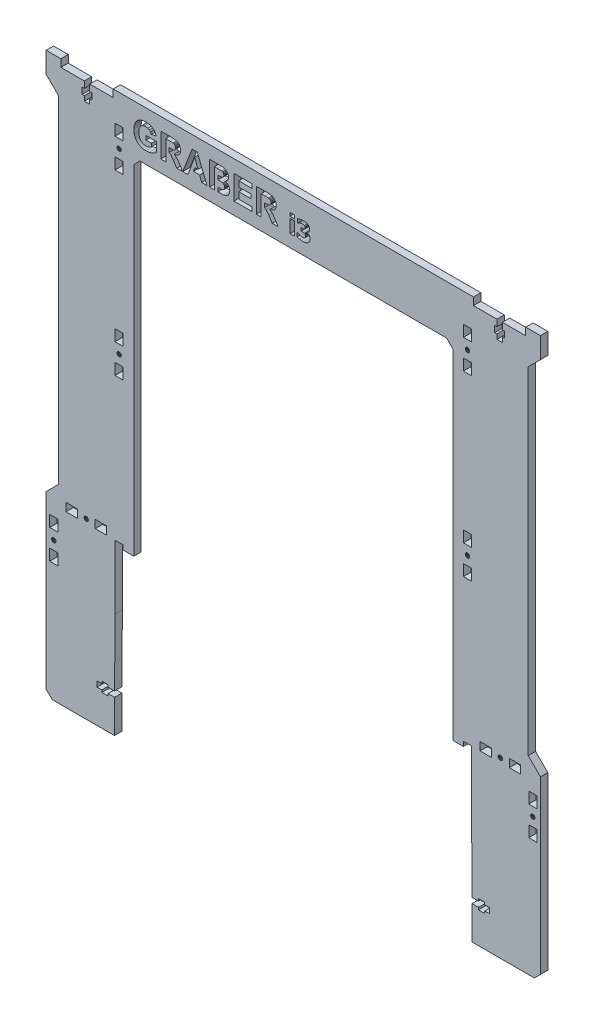
from build123d import *

# Parameters (mm, degrees)
SKETCH1_W           = 9.1999977
SKETCH1_H           = 6.599987016
SKETCH1_W_2         = 9.199995837
SKETCH1_W_3         = 6.600001917
SKETCH1_H_2         = 9.1999977
SKETCH1_W_4         = 6.600001918
SKETCH1_H_3         = 9.199995838
SKETCH1_H_4         = 9.199995837
SKETCH1_W_5         = 9.199997699
SKETCH1_W_6         = 3.544061303
SKETCH1_H_5         = 2.614942529
SKETCH1_W_7         = 3.352490421
SKETCH1_H_6         = 10.756704981
BOSS_EXTRUDE1_DEPTH = 6


with BuildPart() as part:
    # Sketch1 → Boss-Extrude1 (new body)
    with BuildSketch(Plane.XY):
        Polygon((502.477651433, 83.050254715), (493.827654201, 83.050254715), (493.827654201, 359.540924035), (488.827655801, 364.540922435), (238.827735801, 364.540922435), (233.827737401, 359.540924035), (233.827737401, 83.050254715), (225.177740169, 83.050254715), (225.177740169, 86.741023859), (218.477742313, 86.741023859), (218.477742313, 34.550270235), (218.169531771, -19.958979321), (212.869532949, -19.958979321), (212.869532949, -18.158981089), (207.769535184, -18.158981089), (207.769535184, -19.958979321), (203.819535362, -19.958979321), (203.819535362, -24.358983993), (207.769535184, -24.358983993), (207.769535184, -26.158982225), (212.869532949, -26.158982225), (212.869532949, -24.358983993), (218.169531771, -24.358983993), (218.027745865, -51.458971965), (167.377754014, -51.458971965), (162.377755614, -46.650721918), (162.377755614, 93.041023355), (172.377754814, 103.041022555), (172.377754814, 377.540911795), (162.377755614, 387.540910995), (162.377755614, 404.540909635), (174.377752254, 404.540909635), (174.377752254, 398.440911587), (193.477734582, 398.440911587), (193.477734582, 393.140912766), (191.67773635, 393.140912766), (191.67773635, 388.040915001), (193.477734582, 388.040915001), (193.477734582, 384.090915179), (197.877739254, 384.090915179), (197.877739254, 388.040915001), (199.677737486, 388.040915001), (199.677737486, 393.140912766), (197.877739254, 393.140912766), (197.877739254, 398.440911587), (216.977735214, 398.440911587), (216.977735214, 404.540909635), (510.727648313, 404.540909635), (510.727648313, 398.440911587), (529.827644273, 398.440911587), (529.827644273, 393.140912766), (528.027646041, 393.140912766), (528.027646041, 388.040915001), (529.827644273, 388.040915001), (529.827644273, 384.090915179), (534.227648945, 384.090915179), (534.227648945, 388.040915001), (536.027647177, 388.040915001), (536.027647177, 393.140912766), (534.227648945, 393.140912766), (534.227648945, 398.440911587), (553.327631273, 398.440911587), (553.327631273, 404.540909635), (565.327627913, 404.540909635), (565.327627913, 387.540910995), (555.327628713, 377.540911795), (555.327628713, 103.041022555), (565.327627913, 93.041023355), (565.327627913, -46.458973565), (560.327629513, -51.458971965), (509.627645737, -51.458971965), (509.50161394, -24.358983993), (514.801612761, -24.358983993), (514.801612761, -26.158982225), (519.901610526, -26.158982225), (519.901610526, -24.358983993), (523.851610348, -24.358983993), (523.851610348, -19.958979321), (519.901610526, -19.958979321), (519.901610526, -18.158981089), (514.801612761, -18.158981089), (514.801612761, -19.958979321), (509.50161394, -19.958979321), (509.227649273, 34.550270235), (509.227649273, 86.741023859), (502.477651433, 86.741023859), align=None)
        Polygon((223.101753359, 365.909146328), (222.728603849, 366.195474018), (222.294062041, 366.375467128), (221.827741241, 366.436859426), (221.361420441, 366.375467128), (220.926878633, 366.195474018), (220.553729123, 365.909146328), (220.267401433, 365.535996818), (220.087408323, 365.10145501), (220.026016025, 364.635134211), (220.087408323, 364.168813411), (220.267401433, 363.734271603), (220.553729123, 363.361122093), (220.926878633, 363.074794403), (221.361420441, 362.894801293), (221.827741241, 362.833408995), (222.294062041, 362.894801293), (222.728603849, 363.074794403), (223.101753359, 363.361122093), (223.388081048, 363.734271603), (223.568074158, 364.168813411), (223.629466456, 364.635134211), (223.568074158, 365.10145501), (223.388081048, 365.535996818), align=None, mode=Mode.SUBTRACT)
        Polygon((220.026016025, 219.550211035), (220.087408323, 219.083890236), (220.267401433, 218.649348428), (220.553729123, 218.276198918), (220.926878633, 217.989871228), (221.361420441, 217.809878118), (221.827741241, 217.74848582), (222.294062041, 217.809878118), (222.728603849, 217.989871228), (223.101753359, 218.276198918), (223.388081048, 218.649348428), (223.568074158, 219.083890236), (223.629466456, 219.550211035), (223.568074158, 220.016531835), (223.388081048, 220.451073643), (223.101753359, 220.824223153), (222.728603849, 221.110550843), (222.294062041, 221.290543953), (221.827741241, 221.351936251), (221.361420441, 221.290543953), (220.926878633, 221.110550843), (220.553729123, 220.824223153), (220.267401433, 220.451073643), (220.087408323, 220.016531835), align=None, mode=Mode.SUBTRACT)
        Polygon((507.567983278, 364.168813411), (507.629375576, 364.635134211), (507.567983278, 365.10145501), (507.387990168, 365.535996818), (507.101662479, 365.909146328), (506.728512969, 366.195474018), (506.293971161, 366.375467128), (505.827650361, 366.436859426), (505.361329561, 366.375467128), (504.926787753, 366.195474018), (504.553638243, 365.909146328), (504.267310553, 365.535996818), (504.087317443, 365.10145501), (504.025925145, 364.635134211), (504.087317443, 364.168813411), (504.267310553, 363.734271603), (504.553638243, 363.361122093), (504.926787753, 363.074794403), (505.361329561, 362.894801293), (505.827650361, 362.833408995), (506.293971161, 362.894801293), (506.728512969, 363.074794403), (507.101662479, 363.361122093), (507.387990168, 363.734271603), align=None, mode=Mode.SUBTRACT)
        with Locations((183.17775488, 90.090946608)):
            Rectangle(SKETCH1_W, SKETCH1_H, mode=Mode.SUBTRACT)
        with Locations((206.97774571, 90.090946608)):
            Rectangle(SKETCH1_W_2, SKETCH1_H, mode=Mode.SUBTRACT)
        with Locations((559.077635956, 49.890967072)):
            Rectangle(SKETCH1_W_3, SKETCH1_H_2, mode=Mode.SUBTRACT)
        with Locations((221.82774028, 352.735139431)):
            Rectangle(SKETCH1_W_4, SKETCH1_H_2, mode=Mode.SUBTRACT)
        with Locations((221.82774028, 376.535130261)):
            Rectangle(SKETCH1_W_4, SKETCH1_H_3, mode=Mode.SUBTRACT)
        Polygon((559.543957717, 63.531294769), (559.077636918, 63.592687067), (558.611316118, 63.531294769), (558.17677431, 63.351301658), (557.8036248, 63.064973969), (557.51729711, 62.691824459), (557.337304, 62.257282651), (557.275911702, 61.790961851), (557.337304, 61.324641051), (557.51729711, 60.890099243), (557.8036248, 60.516949733), (558.17677431, 60.230622044), (558.611316118, 60.050628933), (559.077636918, 59.989236635), (559.543957717, 60.050628933), (559.978499525, 60.230622044), (560.351649035, 60.516949733), (560.637976725, 60.890099243), (560.817969835, 61.324641051), (560.879362133, 61.790961851), (560.817969835, 62.257282651), (560.637976725, 62.691824459), (560.351649035, 63.064973969), (559.978499525, 63.351301658), align=None, mode=Mode.SUBTRACT)
        Polygon((170.318089523, 61.324641051), (170.379481821, 61.790961851), (170.318089523, 62.257282651), (170.138096413, 62.691824459), (169.851768723, 63.064973969), (169.478619213, 63.351301658), (169.044077406, 63.531294769), (168.577756606, 63.592687067), (168.111435806, 63.531294769), (167.676893998, 63.351301658), (167.303744488, 63.064973969), (167.017416798, 62.691824459), (166.837423688, 62.257282651), (166.77603139, 61.790961851), (166.837423688, 61.324641051), (167.017416798, 60.890099243), (167.303744488, 60.516949733), (167.676893998, 60.230622044), (168.111435806, 60.050628933), (168.577756606, 59.989236635), (169.044077406, 60.050628933), (169.478619213, 60.230622044), (169.851768723, 60.516949733), (170.138096413, 60.890099243), align=None, mode=Mode.SUBTRACT)
        Polygon((193.337416742, 89.624627687), (193.517409852, 89.190085879), (193.803737542, 88.816936369), (194.176887052, 88.530608679), (194.61142886, 88.350615569), (195.077749659, 88.289223271), (195.544070459, 88.350615569), (195.978612267, 88.530608679), (196.351761777, 88.816936369), (196.638089467, 89.190085879), (196.818082577, 89.624627687), (196.879474875, 90.090948487), (196.818082577, 90.557269287), (196.638089467, 90.991811095), (196.351761777, 91.364960605), (195.978612267, 91.651288294), (195.544070459, 91.831281404), (195.077749659, 91.892673702), (194.61142886, 91.831281404), (194.176887052, 91.651288294), (193.803737542, 91.364960605), (193.517409852, 90.991811095), (193.337416742, 90.557269287), (193.276024444, 90.090948487), align=None, mode=Mode.SUBTRACT)
        Polygon((271.976630761, 388.692495359), (271.8953095, 387.634061422), (271.651345717, 386.672039289), (271.244739413, 385.80642896), (270.675490587, 385.037230436), (269.944437602, 384.382887713), (269.052418823, 383.861844789), (267.999434249, 383.474101663), (266.78548388, 383.219658337), (267.960869527, 382.431596633), (268.911573752, 381.56975894), (269.895812518, 380.322274031), (271.171801787, 378.377270677), (273.572874892, 374.540919235), (268.824383947, 374.540919235), (265.953827273, 378.819926613), (263.861271941, 381.710604011), (263.281124389, 382.213622119), (262.667442297, 382.528846801), (262.667442297, 385.889007766), (262.801580459, 385.889007766), (265.122170667, 385.94936994), (266.369655576, 386.130456459), (267.003458393, 386.459094956), (267.483002324, 386.962113065), (267.784813189, 387.626096968), (267.885416811, 388.43763285), (267.752955375, 389.334681811), (267.355571069, 390.04058389), (266.716738071, 390.538571817), (265.85993056, 390.811878323), (262.962546254, 390.878947404), (259.863954705, 390.878947404), (259.863954705, 374.540919235), (255.8934651, 374.540919235), (255.8934651, 394.20557383), (264.250272612, 394.20557383), (266.97160058, 394.073112394), (268.831090855, 393.675728088), (270.117140486, 392.939644923), (271.118146522, 391.791086908), (271.762009701, 390.339041301), align=None, mode=Mode.SUBTRACT)
        with Locations((221.82774028, 231.450207086)):
            Rectangle(SKETCH1_W_4, SKETCH1_H_4, mode=Mode.SUBTRACT)
        with Locations((221.82774028, 207.650216256)):
            Rectangle(SKETCH1_W_4, SKETCH1_H_2, mode=Mode.SUBTRACT)
        Polygon((533.901647358, 91.364960605), (533.528497848, 91.651288294), (533.09395604, 91.831281404), (532.62763524, 91.892673702), (532.16131444, 91.831281404), (531.726772632, 91.651288294), (531.353623122, 91.364960605), (531.067295432, 90.991811095), (530.887302322, 90.557269287), (530.825910024, 90.090948487), (530.887302322, 89.624627687), (531.067295432, 89.190085879), (531.353623122, 88.816936369), (531.726772632, 88.530608679), (532.16131444, 88.350615569), (532.62763524, 88.289223271), (533.09395604, 88.350615569), (533.528497848, 88.530608679), (533.901647358, 88.816936369), (534.187975047, 89.190085879), (534.367968157, 89.624627687), (534.429360455, 90.090948487), (534.367968157, 90.557269287), (534.187975047, 90.991811095), align=None, mode=Mode.SUBTRACT)
        with Locations((168.577755645, 49.890967072)):
            Rectangle(SKETCH1_W_3, SKETCH1_H_2, mode=Mode.SUBTRACT)
        with Locations((168.577755645, 73.690957902)):
            Rectangle(SKETCH1_W_3, SKETCH1_H_4, mode=Mode.SUBTRACT)
        with Locations((520.72764046, 90.090946608)):
            Rectangle(SKETCH1_W_5, SKETCH1_H, mode=Mode.SUBTRACT)
        with Locations((544.527631291, 90.090946608)):
            Rectangle(SKETCH1_W_2, SKETCH1_H, mode=Mode.SUBTRACT)
        with Locations((559.077635956, 73.690957902)):
            Rectangle(SKETCH1_W_3, SKETCH1_H_4, mode=Mode.SUBTRACT)
        Polygon((507.567983278, 220.016531835), (507.387990168, 220.451073643), (507.101662479, 220.824223153), (506.728512969, 221.110550843), (506.293971161, 221.290543953), (505.827650361, 221.351936251), (505.361329561, 221.290543953), (504.926787753, 221.110550843), (504.553638243, 220.824223153), (504.267310553, 220.451073643), (504.087317443, 220.016531835), (504.025925145, 219.550211035), (504.087317443, 219.083890236), (504.267310553, 218.649348428), (504.553638243, 218.276198918), (504.926787753, 217.989871228), (505.361329561, 217.809878118), (505.827650361, 217.74848582), (506.293971161, 217.809878118), (506.728512969, 217.989871228), (507.101662479, 218.276198918), (507.387990168, 218.649348428), (507.567983278, 219.083890236), (507.629375576, 219.550211035), align=None, mode=Mode.SUBTRACT)
        with Locations((505.8276494, 207.650216256)):
            Rectangle(SKETCH1_W_4, SKETCH1_H_2, mode=Mode.SUBTRACT)
        with Locations((505.8276494, 231.450207086)):
            Rectangle(SKETCH1_W_4, SKETCH1_H_4, mode=Mode.SUBTRACT)
        with Locations((505.8276494, 376.535130261)):
            Rectangle(SKETCH1_W_4, SKETCH1_H_3, mode=Mode.SUBTRACT)
        Polygon((236.701647528, 392.009061422), (237.718582471, 392.854970208), (238.88474612, 393.56171065), (239.888267247, 393.990114406), (241.007482538, 394.296117089), (243.592995617, 394.540919235), (245.323797092, 394.444926613), (246.854229688, 394.156948746), (248.184293403, 393.676985634), (249.313988239, 393.005037277), (250.25169783, 392.16373949), (251.005805811, 391.175728088), (251.576312183, 390.041003072), (251.963216945, 388.75956444), (248.019554973, 388.021804547), (247.420963424, 389.31791454), (246.456845382, 390.308860215), (245.167442297, 390.93763285), (243.592995617, 391.147223729), (242.358505342, 391.044105017), (241.257314866, 390.73474888), (240.289424188, 390.219155318), (239.45483331, 389.497324333), (238.782884953, 388.572609376), (238.302921841, 387.448363903), (238.014943974, 386.124587914), (237.918951351, 384.601281408), (238.016201519, 382.960184829), (238.307952022, 381.537901127), (238.79420286, 380.334430302), (239.474954034, 379.349772354), (240.313317548, 378.583927284), (241.272405409, 378.03689509), (242.352217615, 377.708675775), (243.552754168, 377.599269336), (244.801915805, 377.721670409), (246.054430895, 378.088873628), (247.21975618, 378.630456459), (248.2073484, 379.275996365), (248.2073484, 381.770966184), (243.660064698, 381.770966184), (243.660064698, 385.084178793), (252.218079453, 385.084178793), (252.218079453, 377.250510114), (250.69058113, 376.115365915), (248.603055979, 375.124420241), (246.220426871, 374.435285432), (243.807616676, 374.20557383), (242.314491257, 374.286475909), (240.920292733, 374.529182146), (239.625021103, 374.933692542), (238.428676368, 375.500007096), (237.353055979, 376.216807901), (236.419957387, 377.072777049), (235.629380593, 378.06791454), (234.981325597, 379.202220375), (234.476630761, 380.432518833), (234.11613445, 381.715634192), (233.827737401, 384.440315614), (233.908220298, 385.933441033), (234.14966899, 387.341053373), (234.552083477, 388.663152636), (235.115463759, 389.899738819), (235.833941291, 391.023984292), align=None, mode=Mode.SUBTRACT)
        Polygon((307.053760204, 374.675057398), (302.342023115, 374.543075967), (302.342023115, 377.854131844), (303.217408762, 377.854131844), (305.940413457, 377.97485619), (306.743565704, 378.25151615), (307.382398702, 378.75956444), (307.799903732, 379.488940697), (307.939072075, 380.429584561), (307.831761546, 381.247827351), (307.509829956, 381.931931978), (306.985014396, 382.465131174), (306.269051955, 382.830657666), (304.983002324, 383.041925272), (302.747925194, 383.112347807), (302.342023115, 383.112347807), (302.342023115, 386.389917098), (305.028273953, 386.452388048), (305.93873673, 386.688806559), (306.631224993, 387.1566134), (307.068850748, 387.832334393), (307.214725999, 388.692495359), (307.088971472, 389.519121784), (306.71170789, 390.174722052), (306.086288709, 390.632468531), (305.216067381, 390.865533588), (301.822371874, 390.932602669), (299.542023115, 390.932602669), (299.542023115, 374.540919235), (295.571533511, 374.540919235), (295.571533511, 394.20557383), (303.432029822, 394.20557383), (306.912915134, 394.011073494), (307.999434249, 393.710939356), (308.965229017, 393.199537612), (309.795208896, 392.480221717), (310.474283343, 391.556345124), (310.926999641, 390.468149282), (311.077905073, 389.25587564), (310.891788373, 387.931261288), (310.333438273, 386.720664373), (309.456510037, 385.711274701), (308.31465893, 384.990282079), (309.904196153, 384.282703273), (311.077905073, 383.20624452), (311.80225115, 381.834681811), (312.043699842, 380.241791133), (311.887764228, 378.918853508), (311.419957387, 377.632803876), (310.682197495, 376.492629497), (309.716402726, 375.607317626), (308.510835992, 374.99531226), align=None, mode=Mode.SUBTRACT)
        Polygon((341.121499976, 382.213622119), (340.507817884, 382.528846801), (340.504330291, 385.889007766), (340.641956046, 385.889007766), (342.962546254, 385.94936994), (344.210031163, 386.130456459), (344.84383398, 386.459094956), (345.323377911, 386.962113065), (345.625188776, 387.626096968), (345.725792397, 388.43763285), (345.593330962, 389.334681811), (345.195946656, 390.04058389), (344.557113658, 390.538571817), (343.700306147, 390.811878323), (340.802921841, 390.878947404), (337.704330291, 390.878947404), (337.704330291, 374.540919235), (333.733840687, 374.540919235), (333.733840687, 394.20557383), (342.090648199, 394.20557383), (344.811976167, 394.073112394), (346.671466442, 393.675728088), (347.957516073, 392.939644923), (348.958522109, 391.791086908), (349.602385288, 390.339041301), (349.817006348, 388.692495359), (349.735685087, 387.634061422), (349.491721304, 386.672039289), (349.085115, 385.80642896), (348.515866173, 385.037230436), (347.784813189, 384.382887713), (346.892794409, 383.861844789), (345.839809835, 383.474101663), (344.625859467, 383.219658337), (345.801245114, 382.431596633), (346.751949339, 381.56975894), (347.736188105, 380.322274031), (349.012177374, 378.377270677), (351.413250479, 374.540919235), (346.664759534, 374.540919235), (343.79420286, 378.819926613), (341.701647528, 381.710604011), align=None, mode=Mode.SUBTRACT)
        Polygon((282.353999305, 379.00772004), (283.574656582, 382.320932649), (286.141620701, 382.320932649), (283.432029822, 389.618048679), (277.932365167, 374.540919235), (273.720426871, 374.540919235), (281.379715939, 394.20557383), (285.578240419, 394.20557383), (293.452150546, 374.540919235), (289.13290172, 374.540919235), (287.415933242, 379.00772004), align=None, mode=Mode.SUBTRACT)
        Polygon((330.353558997, 374.540919235), (315.3971539, 374.540919235), (315.3971539, 394.20557383), (329.977972143, 394.20557383), (329.977972143, 390.878947404), (319.367643504, 390.878947404), (319.367643504, 386.519457129), (329.24021225, 386.519457129), (329.24021225, 383.20624452), (319.367643504, 383.20624452), (319.367643504, 377.854131844), (330.353558997, 377.854131844), align=None, mode=Mode.SUBTRACT)
        with Locations((505.8276494, 352.735139431)):
            Rectangle(SKETCH1_W_4, SKETCH1_H_2, mode=Mode.SUBTRACT)
        with Locations((363.012054787, 388.137662531)):
            Rectangle(SKETCH1_W_6, SKETCH1_H_5, mode=Mode.SUBTRACT)
        with Locations((363.012054787, 379.919271726)):
            Rectangle(SKETCH1_W_7, SKETCH1_H_6, mode=Mode.SUBTRACT)
        Polygon((371.910522219, 389.100306208), (373.099459001, 389.04522958), (374.118376625, 388.879999695), (374.984037545, 388.609405825), (375.713204212, 388.238237243), (376.350177392, 387.726982454), (376.805158235, 387.093601228), (377.07814674, 386.354856017), (377.169142909, 385.527509274), (376.993137162, 384.386465212), (376.46511992, 383.39628322), (375.649746357, 382.643170193), (374.611671645, 382.213333028), (374.611671645, 382.079233412), (375.603050955, 381.820612722), (376.546537545, 381.22674299), (376.940455169, 380.799300461), (377.260139077, 380.264099312), (377.472064365, 379.618744906), (377.542706127, 378.860842607), (377.445723369, 377.862279389), (377.154775093, 376.954712339), (376.677045208, 376.157298546), (376.019717622, 375.489195097), (375.19716015, 374.956388584), (374.242897698, 374.564865595), (373.111432181, 374.324204676), (371.757265514, 374.243984369), (370.20913333, 374.313428814), (368.898070112, 374.521762147), (366.95841494, 375.144367511), (366.95841494, 378.238237243), (367.303242526, 378.238237243), (368.156930265, 377.773677856), (369.147112258, 377.376168277), (370.158845974, 377.103179772), (371.077188886, 377.012183603), (372.202667813, 377.103179772), (372.761815323, 377.248055251), (373.222782756, 377.50068935), (373.744813407, 378.08976981), (373.892083522, 378.512423067), (373.94117356, 379.08114912), (373.871729116, 379.64029663), (373.663395782, 380.053371343), (373.34011992, 380.346714254), (372.92584789, 380.546666362), (371.824315323, 380.728658699), (370.694047123, 380.747815787), (370.081020304, 380.747815787), (370.081020304, 383.257394331), (370.646154403, 383.257394331), (371.843472411, 383.314865595), (372.772591185, 383.544750653), (373.371250189, 384.052413488), (373.53288812, 384.435555251), (373.58676743, 384.933639542), (373.536480074, 385.32516253), (373.385618005, 385.63766253), (372.887533713, 386.063907741), (372.082936012, 386.293792799), (371.297495399, 386.351264063), (370.224698464, 386.22674299), (369.161480074, 385.910651036), (368.318568196, 385.513141458), (367.6672272, 385.144367511), (367.370292334, 385.144367511), (367.370292334, 388.199923067), (369.357840227, 388.808160615), (370.621010725, 389.02726981), align=None, mode=Mode.SUBTRACT)
    extrude(amount=BOSS_EXTRUDE1_DEPTH)


solid = part.part
